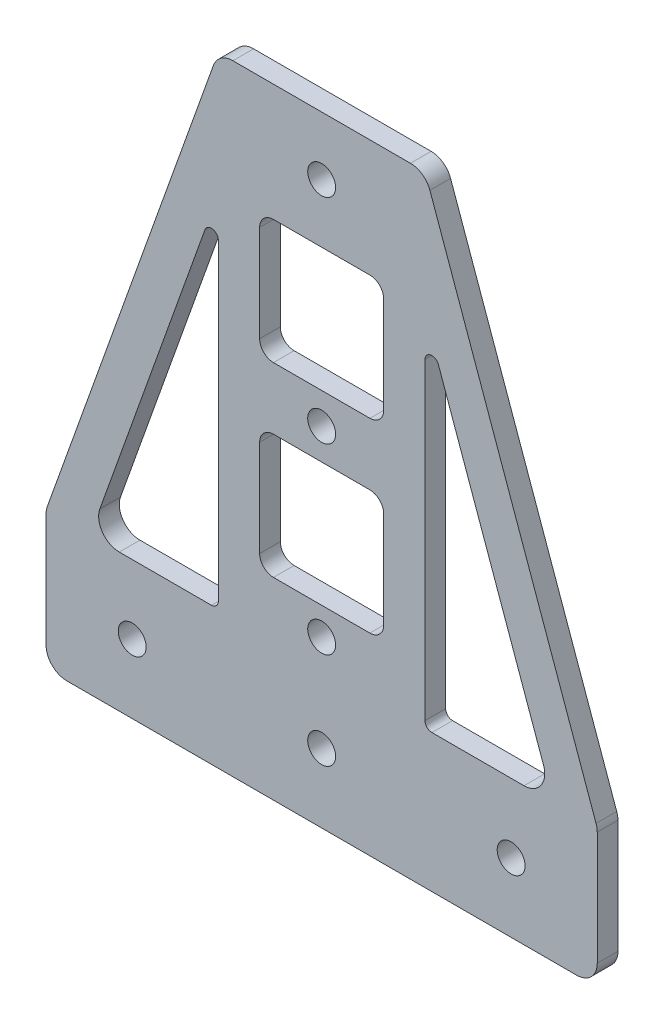
from build123d import *

# Parameters (mm, degrees)
EXTRUDE_1_DEPTH          = 1.5
SKETCH_2_W               = 18
SKETCH_2_H               = 18
CUT_EXTRUDE_1_DEPTH      = 3
FILLET_1_R               = 1
FILLET_2_R               = 2
FILLET_3_R               = 3
SKETCH_3_R               = 2.025
CUT_EXTRUDE_2_DEPTH      = 1
CUT_EXTRUDE_2_DEPTH_BACK = 4
SKETCH_4_R               = 2.025
CUT_EXTRUDE_3_DEPTH      = 1
CUT_EXTRUDE_3_DEPTH_BACK = 4
SKETCH_5_R               = 2.025
CUT_EXTRUDE_4_DEPTH      = 1
CUT_EXTRUDE_4_DEPTH_BACK = 4
FILLET_4_R               = 3


with BuildPart() as part:
    # 草图1 → 凸台-拉伸1 (new body, symmetric)
    with BuildSketch(Plane.XY):
        Polygon((40, 0), (-40, 0), (-40, 20), (-15, 90), (15, 90), (40, 20), align=None)
    extrude(amount=EXTRUDE_1_DEPTH, both=True)

    # 草图2 → 切除-拉伸1 (cut)
    with BuildSketch(Plane.XY.offset(1.5)):
        Polygon((-15, 72.160717503), (-33.62882768, 20), (-15, 20), align=None)
        with Locations((0, 64)):
            Rectangle(SKETCH_2_W, SKETCH_2_H)
        with Locations((0, 37)):
            Rectangle(SKETCH_2_W, SKETCH_2_H)
        Polygon((15, 20), (15, 72.160717503), (33.62882768, 20), align=None)
    extrude(amount=-CUT_EXTRUDE_1_DEPTH, mode=Mode.SUBTRACT)

    # 圆角1
    fillet_1_edges = [part.edges().sort_by_distance(p)[0] for p in [
        (-15, 20, 0),
        (-15, 72.160717503, 0),
        (15, 72.160717503, 0),
        (15, 20, 0),
    ]]
    fillet(fillet_1_edges, radius=FILLET_1_R)

    # 圆角2
    fillet_2_edges = [part.edges().sort_by_distance(p)[0] for p in [
        (-9, 46, 0),
        (-9, 28, 0),
        (9, 28, 0),
        (9, 46, 0),
        (-9, 73, 0),
        (-9, 55, 0),
        (9, 55, 0),
        (9, 73, 0),
    ]]
    fillet(fillet_2_edges, radius=FILLET_2_R)

    # 圆角3
    fillet_3_edges = [part.edges().sort_by_distance(p)[0] for p in [
        (40, 0, 0),
        (-40, 0, 0),
        (-40, 20, 0),
        (-15, 90, 0),
        (15, 90, 0),
        (40, 20, 0),
    ]]
    fillet(fillet_3_edges, radius=FILLET_3_R)

    # 草图3 → 切除-拉伸2 (cut, two sides)
    with BuildSketch(Plane.XY.offset(1.5)) as cut_extrude_2_sk:
        with Locations((-27.5, 10)):
            Circle(SKETCH_3_R)
        with Locations((27.5, 10)):
            Circle(SKETCH_3_R)
    extrude(amount=CUT_EXTRUDE_2_DEPTH, mode=Mode.SUBTRACT)
    extrude(cut_extrude_2_sk.sketch, amount=-CUT_EXTRUDE_2_DEPTH_BACK, mode=Mode.SUBTRACT)

    # 草图4 → 切除-拉伸3 (cut, two sides)
    with BuildSketch(Plane.XY.offset(1.5)) as cut_extrude_3_sk:
        with Locations((0, 10)):
            Circle(SKETCH_4_R)
    extrude(amount=CUT_EXTRUDE_3_DEPTH, mode=Mode.SUBTRACT)
    extrude(cut_extrude_3_sk.sketch, amount=-CUT_EXTRUDE_3_DEPTH_BACK, mode=Mode.SUBTRACT)

    # 草图5 → 切除-拉伸4 (cut, two sides)
    with BuildSketch(Plane.XY.offset(1.5)) as cut_extrude_4_sk:
        with Locations((0, 24)):
            Circle(SKETCH_5_R)
        with Locations((0, 50.5)):
            Circle(SKETCH_5_R)
        with Locations((0, 81.5)):
            Circle(SKETCH_5_R)
    extrude(amount=CUT_EXTRUDE_4_DEPTH, mode=Mode.SUBTRACT)
    extrude(cut_extrude_4_sk.sketch, amount=-CUT_EXTRUDE_4_DEPTH_BACK, mode=Mode.SUBTRACT)

    # 圆角4
    fillet_4_edges = [part.edges().sort_by_distance(p)[0] for p in [
        (-33.62882768, 20, 0),
        (33.62882768, 20, 0),
    ]]
    fillet(fillet_4_edges, radius=FILLET_4_R)


solid = part.part
